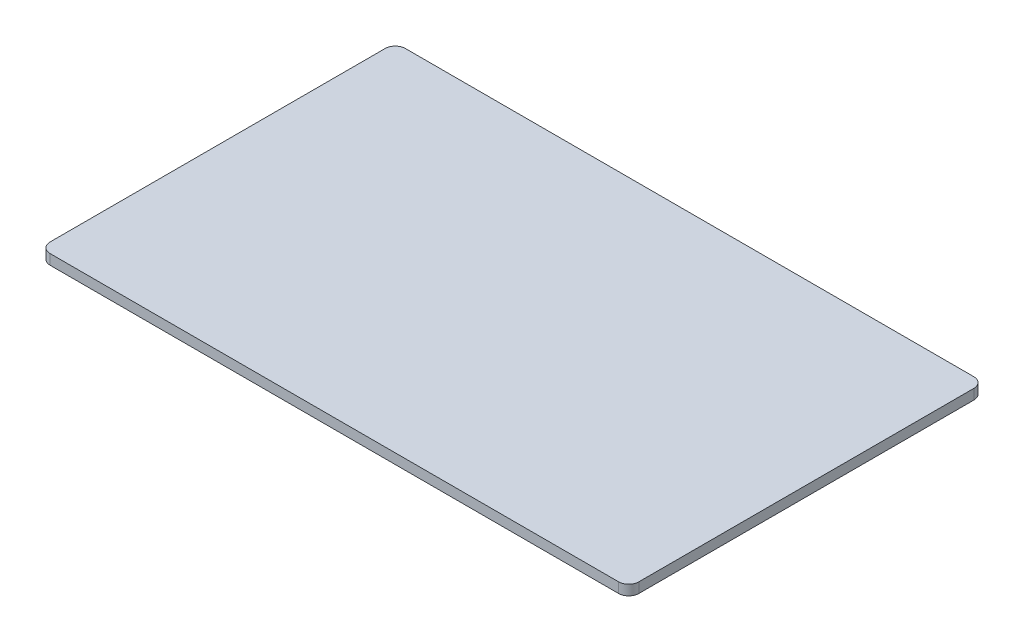
from build123d import *

# Parameters (mm, degrees)
SKETCH1_W           = 147.32
SKETCH1_H           = 88.9
EXTRUDE_THIN1_DEPTH = 2.54
FILLET1_R           = 2.54


with BuildPart() as part:
    # Sketch1 → Extrude-Thin1 (new body)
    with BuildSketch(Plane(origin=(0, 0, 0), x_dir=(1, 0, 0), z_dir=(0, 1, 0))):
        with Locations((0, -44.45)):
            Rectangle(SKETCH1_W, SKETCH1_H)
    extrude(amount=EXTRUDE_THIN1_DEPTH)

    # Fillet1
    fillet1_edges = [part.edges().sort_by_distance(p)[0] for p in [
        (-73.66, 1.27, 88.9),
        (-73.66, 1.27, 0),
        (73.66, 1.27, 0),
        (73.66, 1.27, 88.9),
    ]]
    fillet(fillet1_edges, radius=FILLET1_R)


solid = part.part
